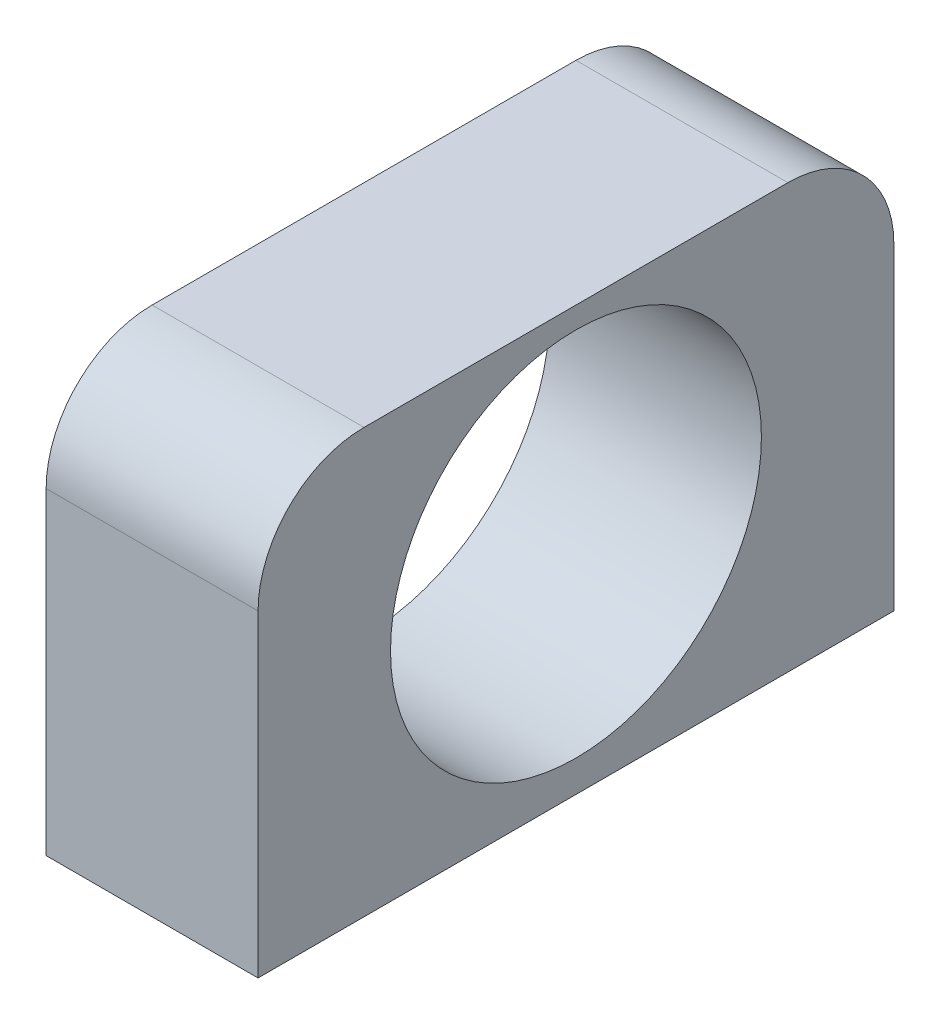
from build123d import *

# Parameters (mm, degrees)
SKETCH1_W           = 12.7
SKETCH1_H           = 38.1
BOSS_EXTRUDE1_DEPTH = 25.4
FILLET1_R           = 6.35
SKETCH2_R           = 11.1125
CUT_EXTRUDE1_DEPTH  = 13.7


with BuildPart() as part:
    # Sketch1 → Boss-Extrude1 (new body)
    with BuildSketch(Plane(origin=(0, 0, 0), x_dir=(1, 0, 0), z_dir=(0, 1, 0))):
        Rectangle(SKETCH1_W, SKETCH1_H)
    extrude(amount=BOSS_EXTRUDE1_DEPTH)

    # Fillet1
    fillet1_edges = [part.edges().sort_by_distance(p)[0] for p in [
        (0, 25.4, 19.05),
        (0, 25.4, -19.05),
    ]]
    fillet(fillet1_edges, radius=FILLET1_R)

    # Sketch2 → Cut-Extrude1 (cut, through all)
    with BuildSketch(Plane.ZY.offset(6.35)):
        with Locations((0, 13)):
            Circle(SKETCH2_R)
    extrude(amount=-CUT_EXTRUDE1_DEPTH, mode=Mode.SUBTRACT)


solid = part.part
